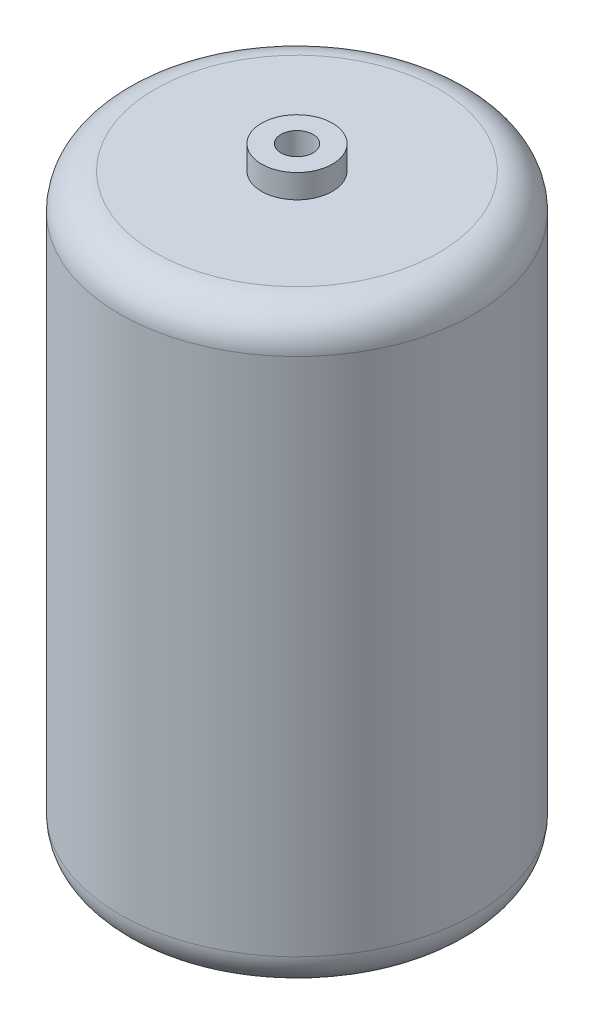
from build123d import *

# Parameters (mm, degrees)
SKETCH1_R                 = 19.05
BOSS_EXTRUDE1_DEPTH       = 63.5
FILLET1_R                 = 3.81
SKETCH2_R                 = 3.81
BOSS_EXTRUDE2_DEPTH       = 2.54
F_8_32_TAPPED_HOLE1_D     = 3.4544
F_8_32_TAPPED_HOLE1_DEPTH = 12.53744
F_8_32_TAPPED_HOLE1_TIP   = 1.037806461
SKETCH6_W                 = 16.907326274
SKETCH6_H                 = 52.824444264


with BuildPart() as part:
    # Sketch1 → Boss-Extrude1 (new body)
    with BuildSketch(Plane(origin=(0, 0, 0), x_dir=(1, 0, 0), z_dir=(0, 1, 0))):
        Circle(SKETCH1_R)
    extrude(amount=BOSS_EXTRUDE1_DEPTH)

    # Fillet1
    fillet1_edges = [part.edges().sort_by_distance(p)[0] for p in [
        (-19.05, 0, 0),
        (-19.05, 63.5, 0),
    ]]
    fillet(fillet1_edges, radius=FILLET1_R)

    # Sketch2 → Boss-Extrude2 (add)
    with BuildSketch(Plane(origin=(0, 63.5, 0), x_dir=(1, 0, 0), z_dir=(0, 1, 0))):
        Circle(SKETCH2_R)
    extrude(amount=BOSS_EXTRUDE2_DEPTH)

    # #8-32 Tapped Hole1
    with Locations(Plane(origin=(0, 66.04, 0), x_dir=(1, 0, 0), z_dir=(0, 1, 0))):
        with Locations((0, 0)):
            Hole(F_8_32_TAPPED_HOLE1_D / 2, depth=F_8_32_TAPPED_HOLE1_DEPTH)
            with Locations((0, 0, -(F_8_32_TAPPED_HOLE1_DEPTH + F_8_32_TAPPED_HOLE1_TIP / 2))):  # 118° drill point
                Cone(0, F_8_32_TAPPED_HOLE1_D / 2, F_8_32_TAPPED_HOLE1_TIP, mode=Mode.SUBTRACT)

    # Sketch6 → Cut-Revolve1 (revolve, cut)
    with BuildSketch(Plane(origin=(0, 0, 0), x_dir=(0, 0, -1), z_dir=(1, 0, 0))):
        with Locations((8.453663137, 31.924965915)):
            Rectangle(SKETCH6_W, SKETCH6_H)
    revolve(axis=Axis((0, 5.512743783, 0), (0, 1, 0)), mode=Mode.SUBTRACT)


solid = part.part
